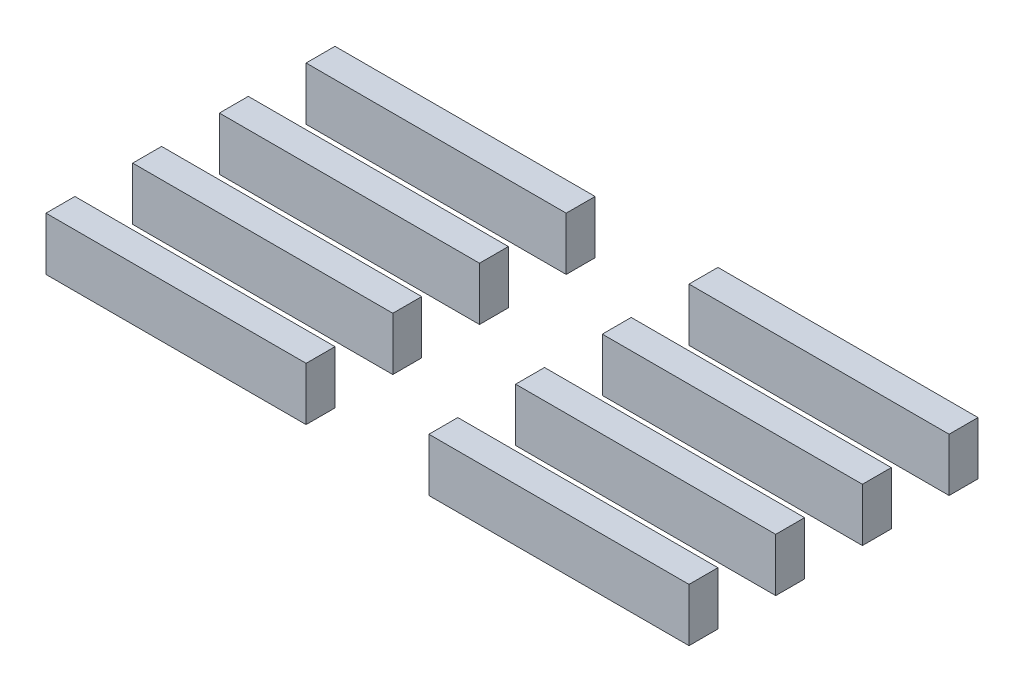
from build123d import *

# Parameters (mm, degrees)
SKETCH1_W             = 36
SKETCH1_H             = 4
BOSS_EXTRUDE1_DEPTH   = 7.35
BOSS_EXTRUDE1_2_DEPTH = 7.35
BOSS_EXTRUDE1_3_DEPTH = 7.35
BOSS_EXTRUDE1_4_DEPTH = 7.35
BOSS_EXTRUDE1_5_DEPTH = 7.35
BOSS_EXTRUDE1_6_DEPTH = 7.35
BOSS_EXTRUDE1_7_DEPTH = 7.35
BOSS_EXTRUDE1_8_DEPTH = 7.35


with BuildPart() as part:
    # Sketch1 → Boss-Extrude1 (new body)
    with BuildSketch(Plane(origin=(0, 0, 0), x_dir=(1, 0, 0), z_dir=(0, 1, 0))):
        with Locations((24.5, 20.5)):
            Rectangle(SKETCH1_W, SKETCH1_H)
    extrude(amount=BOSS_EXTRUDE1_DEPTH)


with BuildPart() as body_2:
    # Sketch1 → Boss-Extrude1 2 (new body)
    with BuildSketch(Plane(origin=(0, 0, 0), x_dir=(1, 0, 0), z_dir=(0, 1, 0))):
        with Locations((24.5, 8.5)):
            Rectangle(SKETCH1_W, SKETCH1_H)
    extrude(amount=BOSS_EXTRUDE1_2_DEPTH)


with BuildPart() as body_3:
    # Sketch1 → Boss-Extrude1 3 (new body)
    with BuildSketch(Plane(origin=(0, 0, 0), x_dir=(1, 0, 0), z_dir=(0, 1, 0))):
        with Locations((24.5, 32.5)):
            Rectangle(SKETCH1_W, SKETCH1_H)
    extrude(amount=BOSS_EXTRUDE1_3_DEPTH)


with BuildPart() as body_4:
    # Sketch1 → Boss-Extrude1 4 (new body)
    with BuildSketch(Plane(origin=(0, 0, 0), x_dir=(1, 0, 0), z_dir=(0, 1, 0))):
        with Locations((24.5, 44.5)):
            Rectangle(SKETCH1_W, SKETCH1_H)
    extrude(amount=BOSS_EXTRUDE1_4_DEPTH)


with BuildPart() as body_5:
    # Sketch1 → Boss-Extrude1 5 (new body)
    with BuildSketch(Plane(origin=(0, 0, 0), x_dir=(1, 0, 0), z_dir=(0, 1, 0))):
        with Locations((77.5, 8.5)):
            Rectangle(SKETCH1_W, SKETCH1_H)
    extrude(amount=BOSS_EXTRUDE1_5_DEPTH)


with BuildPart() as body_6:
    # Sketch1 → Boss-Extrude1 6 (new body)
    with BuildSketch(Plane(origin=(0, 0, 0), x_dir=(1, 0, 0), z_dir=(0, 1, 0))):
        with Locations((77.5, 20.5)):
            Rectangle(SKETCH1_W, SKETCH1_H)
    extrude(amount=BOSS_EXTRUDE1_6_DEPTH)


with BuildPart() as body_7:
    # Sketch1 → Boss-Extrude1 7 (new body)
    with BuildSketch(Plane(origin=(0, 0, 0), x_dir=(1, 0, 0), z_dir=(0, 1, 0))):
        with Locations((77.5, 32.5)):
            Rectangle(SKETCH1_W, SKETCH1_H)
    extrude(amount=BOSS_EXTRUDE1_7_DEPTH)


with BuildPart() as body_8:
    # Sketch1 → Boss-Extrude1 8 (new body)
    with BuildSketch(Plane(origin=(0, 0, 0), x_dir=(1, 0, 0), z_dir=(0, 1, 0))):
        with Locations((77.5, 44.5)):
            Rectangle(SKETCH1_W, SKETCH1_H)
    extrude(amount=BOSS_EXTRUDE1_8_DEPTH)


solid = Compound([part.part, body_2.part, body_3.part, body_4.part, body_5.part, body_6.part, body_7.part, body_8.part])
